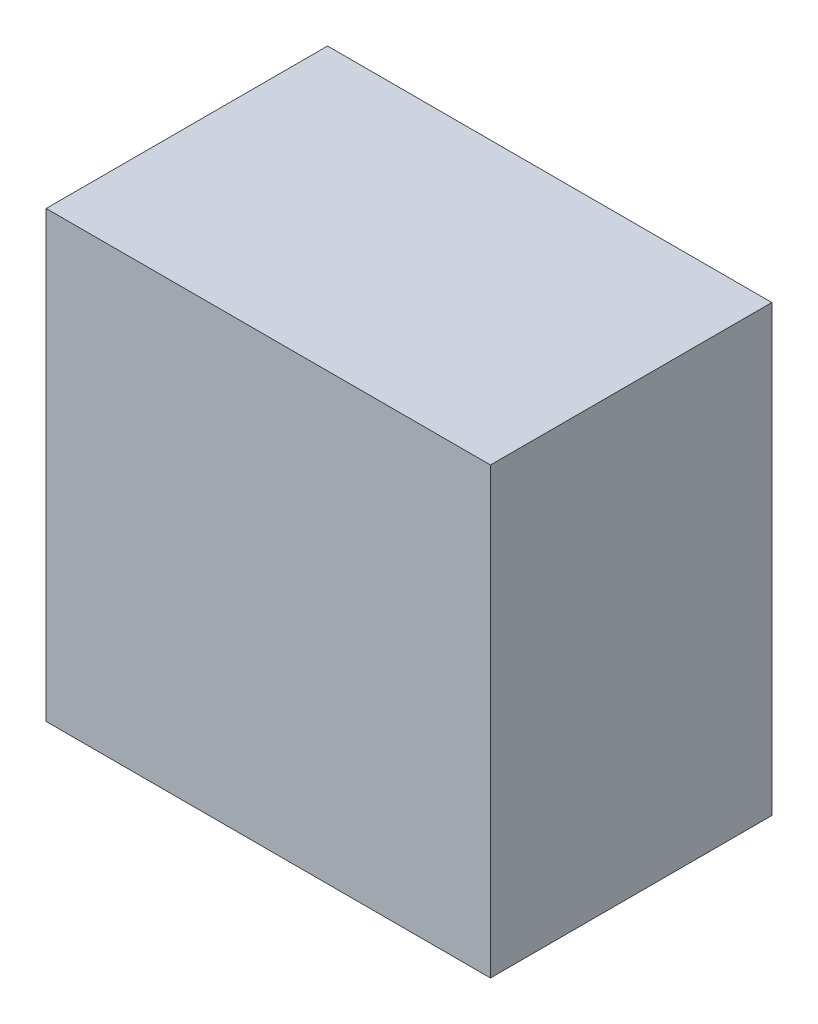
from build123d import *

# Parameters (mm, degrees)
SKETCH1_W           = 60
SKETCH1_H           = 60
BOSS_EXTRUDE1_DEPTH = 38


with BuildPart() as part:
    # Sketch1 → Boss-Extrude1 (new body)
    with BuildSketch(Plane.XY):
        with Locations((30, 30)):
            Rectangle(SKETCH1_W, SKETCH1_H)
    extrude(amount=BOSS_EXTRUDE1_DEPTH)


solid = part.part
